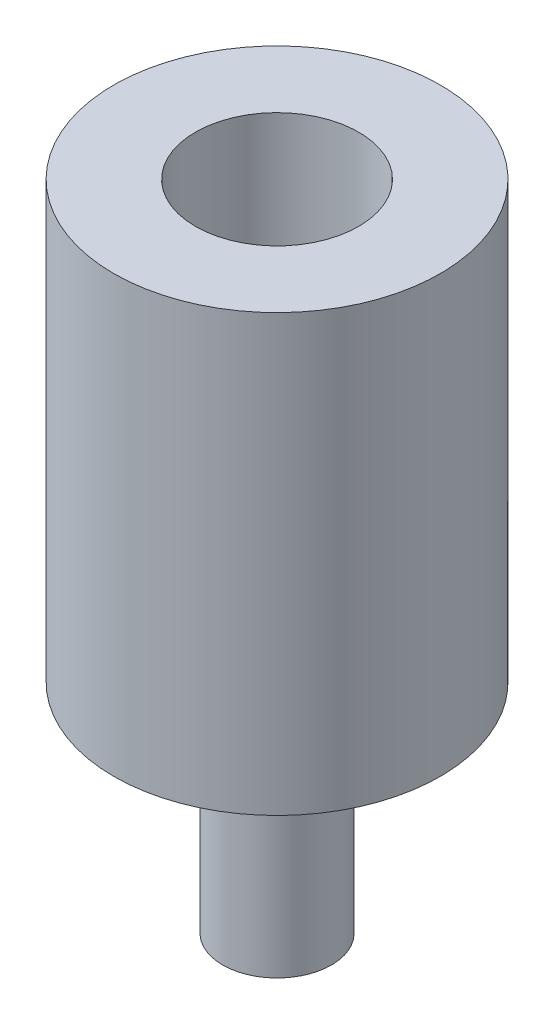
from build123d import *

# Parameters (mm, degrees)
SKETCH1_R           = 2.5
BOSS_EXTRUDE2_DEPTH = 10
SKETCH2_R           = 7.5
BOSS_EXTRUDE3_DEPTH = 20
SKETCH3_R           = 3.75
CUT_EXTRUDE1_DEPTH  = 14


with BuildPart() as part:
    # Sketch1 → Boss-Extrude2 (new body)
    with BuildSketch(Plane(origin=(0, 0, 0), x_dir=(1, 0, 0), z_dir=(0, 1, 0))):
        with Locations(Location((0, 0, 0), (0, 0, 270))):  # turned: the seam where the file's is
            Circle(SKETCH1_R)
    extrude(amount=BOSS_EXTRUDE2_DEPTH)

    # Sketch2 → Boss-Extrude3 (add)
    with BuildSketch(Plane(origin=(0, 10, 0), x_dir=(1, 0, 0), z_dir=(0, 1, 0))):
        with Locations(Location((0, 0, 0), (0, 0, 270))):  # turned: the seam where the file's is
            Circle(SKETCH2_R)
    extrude(amount=BOSS_EXTRUDE3_DEPTH)

    # Sketch3 → Cut-Extrude1 (cut)
    with BuildSketch(Plane(origin=(0, 30, 0), x_dir=(1, 0, 0), z_dir=(0, 1, 0))):
        with Locations(Location((0, 0, 0), (0, 0, 270))):  # turned: the seam where the file's is
            Circle(SKETCH3_R)
    extrude(amount=-CUT_EXTRUDE1_DEPTH, mode=Mode.SUBTRACT)


solid = part.part
